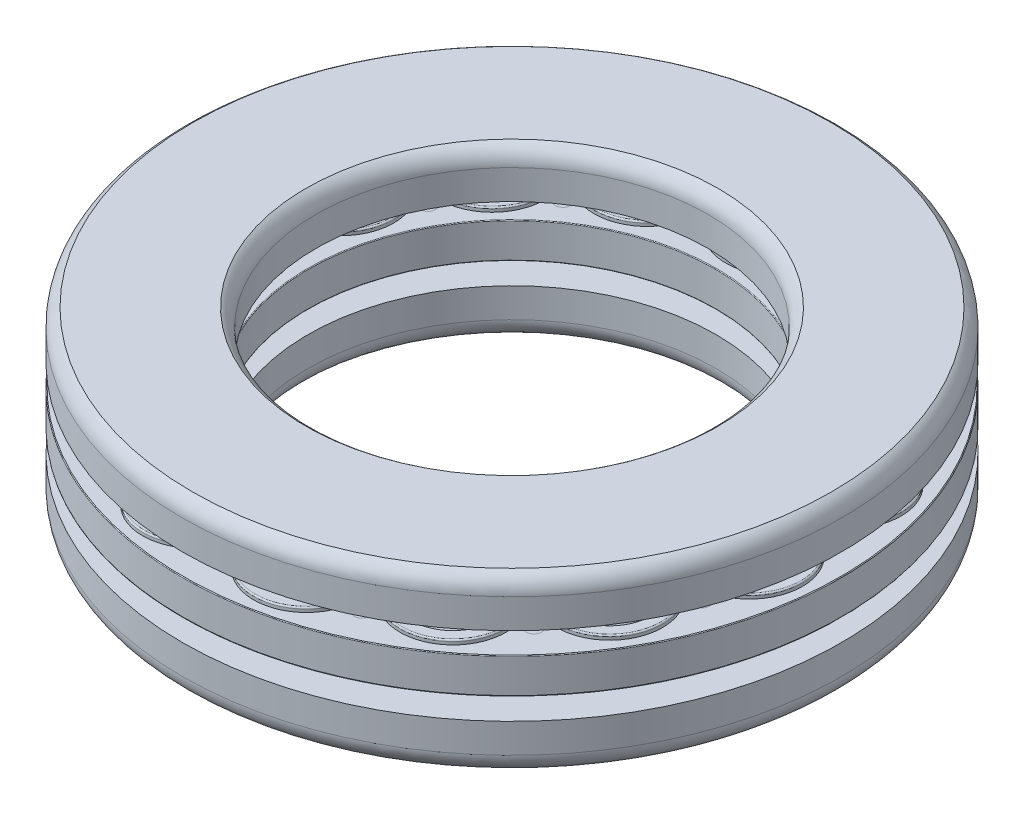
from build123d import *

# Parameters (mm, degrees)
CUT_EXTRUDE1_REACH             = 7.5
CUT_EXTRUDE1_DIRECTION_2_DEPTH = 6.5
SKETCH7_R                      = 0.4995
CUT_EXTRUDE2_DEPTH             = 0.01
CIRPATTERN1_COUNT              = 15
CIRPATTERN2_COUNT              = 15


with BuildPart() as part:
    # Sketch3 → Revolve1 (revolve)
    with BuildSketch(Plane(origin=(0, 0, 0), x_dir=(0, 0, -1), z_dir=(1, 0, 0))):
        with BuildLine():
            Line((21, 2.5), (18.658312395, 2.5))
            ThreePointArc((18.658312395, 2.5), (17, 3), (15.341687605, 2.5))
            Line((15.341687605, 2.5), (12.5, 2.5))
            Line((12.5, 2.5), (12.5, 4.375))
            ThreePointArc((12.5, 4.375), (12.669058766, 5.02038296), (13.1328125, 5.5))
            Line((13.1328125, 5.5), (20.3671875, 5.5))
            ThreePointArc((20.3671875, 5.5), (20.830941234, 5.02038296), (21, 4.375))
            Line((21, 4.375), (21, 2.5))
        make_face()
        with BuildLine():
            Line((15.341687605, -2.5), (13, -2.5))
            Line((13, -2.5), (13, -4.375))
            ThreePointArc((13, -4.375), (13.169058766, -5.02038296), (13.6328125, -5.5))
            Line((13.6328125, -5.5), (20.3671875, -5.5))
            ThreePointArc((20.3671875, -5.5), (20.830941234, -5.02038296), (21, -4.375))
            Line((21, -4.375), (21, -2.5))
            Line((21, -2.5), (18.658312395, -2.5))
            ThreePointArc((18.658312395, -2.5), (17, -3), (15.341687605, -2.5))
        make_face()
        with BuildLine():
            Line((15.875, 1.125), (15.875, 1.31625))
            ThreePointArc((15.875, 1.31625), (15.90136039, 1.37988961), (15.965, 1.40625))
            Line((15.965, 1.40625), (18.035, 1.40625))
            ThreePointArc((18.035, 1.40625), (18.09863961, 1.37988961), (18.125, 1.31625))
            Line((18.125, 1.31625), (18.125, 1.125))
            Line((18.125, 1.125), (20.955, 1.125))
            ThreePointArc((20.955, 1.125), (20.986819805, 1.111819805), (21, 1.08))
            Line((21, 1.08), (21, -1.08))
            ThreePointArc((21, -1.08), (20.986819805, -1.111819805), (20.955, -1.125))
            Line((20.955, -1.125), (18.125, -1.125))
            Line((18.125, -1.125), (18.125, -1.31625))
            ThreePointArc((18.125, -1.31625), (18.09863961, -1.37988961), (18.035, -1.40625))
            Line((18.035, -1.40625), (15.965, -1.40625))
            ThreePointArc((15.965, -1.40625), (15.90136039, -1.37988961), (15.875, -1.31625))
            Line((15.875, -1.31625), (15.875, -1.125))
            Line((15.875, -1.125), (13.045, -1.125))
            ThreePointArc((13.045, -1.125), (13.013180195, -1.111819805), (13, -1.08))
            Line((13, -1.08), (13, 1.08))
            ThreePointArc((13, 1.08), (13.013180195, 1.111819805), (13.045, 1.125))
            Line((13.045, 1.125), (15.875, 1.125))
        make_face()
    revolve(axis=Axis((0, -5.5, 0), (0, 1, 0)))

    # Sketch4 → Revolve2 (revolve)
    with BuildSketch(Plane(origin=(0, 0, 0), x_dir=(0, 0, -1), z_dir=(1, 0, 0))):
        with BuildLine():
            Line((17, 1.40625), (13.715, 1.40625))
            ThreePointArc((13.715, 1.40625), (13.65136039, 1.37988961), (13.625, 1.31625))
            Line((13.625, 1.31625), (13.625, 1.125))
            Line((13.625, 1.125), (17, 1.125))
            Line((17, 1.125), (17, 1.40625))
        make_face()
        with BuildLine():
            Line((13.625, -1.31625), (13.625, -1.125))
            Line((13.625, -1.125), (17, -1.125))
            Line((17, -1.125), (17, -1.40625))
            Line((17, -1.40625), (13.715, -1.40625))
            ThreePointArc((13.715, -1.40625), (13.65136039, -1.37988961), (13.625, -1.31625))
        make_face()
    revolve(axis=Axis((0, 5.5, -17), (0, -1, 0)))

    # Sketch5 → Cut-Extrude1 (cut, up to next)
    with BuildSketch(Plane(origin=(0, 0, 0), x_dir=(1, 0, 0), z_dir=(0, 1, 0)), mode=Mode.PRIVATE) as cut_extrude1_sk1:
        with BuildLine():
            Line((4.911913696, 23.108737067), (0, 0))
            Line((0, 0), (-4.911913696, 23.108737067))
            ThreePointArc((-4.911913696, 23.108737067), (0, -23.625), (4.911913696, 23.108737067))
        make_face()
    cut_extrude1_tool1 = extrude(cut_extrude1_sk1.sketch, amount=-CUT_EXTRUDE1_REACH, mode=Mode.PRIVATE) & part.part
    add(cut_extrude1_tool1.solids().sort_by_distance((0, 0, 1.116793))[0], mode=Mode.SUBTRACT)

    # Sketch5 → Cut-Extrude1 direction 2 (cut)
    with BuildSketch(Plane(origin=(0, 0, 0), x_dir=(1, 0, 0), z_dir=(0, 1, 0))):
        with BuildLine():
            Line((4.911913696, 23.108737067), (0, 0))
            Line((0, 0), (-4.911913696, 23.108737067))
            ThreePointArc((-4.911913696, 23.108737067), (0, -23.625), (4.911913696, 23.108737067))
        make_face()
    extrude(amount=CUT_EXTRUDE1_DIRECTION_2_DEPTH, mode=Mode.SUBTRACT)


with BuildPart() as body_2:
    # Sketch6 → Revolve3 (revolve)
    with BuildSketch(Plane(origin=(0, 0, 0), x_dir=(0, 0, -1), z_dir=(1, 0, 0))):
        with BuildLine():
            Line((17, -3), (17, 3))
            ThreePointArc((17, 3), (14, 0), (17, -3))
        make_face()
    revolve(axis=Axis((0, 5.5, -17), (0, -1, 0)))


with BuildPart() as part_1:
    add(part.part)

    # Combine1: cut body 2
    add(body_2.part, mode=Mode.SUBTRACT)

    # Sketch7 → Cut-Extrude2 (cut)
    with BuildSketch(Plane(origin=(0, 1.125, 0), x_dir=(1, 0, 0), z_dir=(0, 1, 0))):
        with Locations((-3.914587304, 18.416685295)):
            Circle(SKETCH7_R)
        with Locations((-3.04988583, 14.348584707)):
            Circle(SKETCH7_R)
        with Locations((3.04988583, 14.348584707)):
            Circle(SKETCH7_R)
        with Locations((3.914587304, 18.416685295)):
            Circle(SKETCH7_R)
    extrude(amount=-CUT_EXTRUDE2_DEPTH, mode=Mode.SUBTRACT)


with BuildPart() as cirpattern1_1:
    # CirPattern1: pattern copy
    add(part_1.part.rotate(Axis((0, 0, 0), (0, 1, 0)), 1 * 360 / CIRPATTERN1_COUNT))


with BuildPart() as cirpattern1_2:
    # CirPattern1: pattern copy
    add(part_1.part.rotate(Axis((0, 0, 0), (0, 1, 0)), 2 * 360 / CIRPATTERN1_COUNT))


with BuildPart() as cirpattern1_3:
    # CirPattern1: pattern copy
    add(part_1.part.rotate(Axis((0, 0, 0), (0, 1, 0)), 3 * 360 / CIRPATTERN1_COUNT))


with BuildPart() as cirpattern1_4:
    # CirPattern1: pattern copy
    add(part_1.part.rotate(Axis((0, 0, 0), (0, 1, 0)), 4 * 360 / CIRPATTERN1_COUNT))


with BuildPart() as cirpattern1_5:
    # CirPattern1: pattern copy
    add(part_1.part.rotate(Axis((0, 0, 0), (0, 1, 0)), 5 * 360 / CIRPATTERN1_COUNT))


with BuildPart() as cirpattern1_6:
    # CirPattern1: pattern copy
    add(part_1.part.rotate(Axis((0, 0, 0), (0, 1, 0)), 6 * 360 / CIRPATTERN1_COUNT))


with BuildPart() as cirpattern1_7:
    # CirPattern1: pattern copy
    add(part_1.part.rotate(Axis((0, 0, 0), (0, 1, 0)), 7 * 360 / CIRPATTERN1_COUNT))


with BuildPart() as cirpattern1_8:
    # CirPattern1: pattern copy
    add(part_1.part.rotate(Axis((0, 0, 0), (0, 1, 0)), 8 * 360 / CIRPATTERN1_COUNT))


with BuildPart() as cirpattern1_9:
    # CirPattern1: pattern copy
    add(part_1.part.rotate(Axis((0, 0, 0), (0, 1, 0)), 9 * 360 / CIRPATTERN1_COUNT))


with BuildPart() as cirpattern1_10:
    # CirPattern1: pattern copy
    add(part_1.part.rotate(Axis((0, 0, 0), (0, 1, 0)), 10 * 360 / CIRPATTERN1_COUNT))


with BuildPart() as cirpattern1_11:
    # CirPattern1: pattern copy
    add(part_1.part.rotate(Axis((0, 0, 0), (0, 1, 0)), 11 * 360 / CIRPATTERN1_COUNT))


with BuildPart() as cirpattern1_12:
    # CirPattern1: pattern copy
    add(part_1.part.rotate(Axis((0, 0, 0), (0, 1, 0)), 12 * 360 / CIRPATTERN1_COUNT))


with BuildPart() as cirpattern1_13:
    # CirPattern1: pattern copy
    add(part_1.part.rotate(Axis((0, 0, 0), (0, 1, 0)), 13 * 360 / CIRPATTERN1_COUNT))


with BuildPart() as cirpattern1_14:
    # CirPattern1: pattern copy
    add(part_1.part.rotate(Axis((0, 0, 0), (0, 1, 0)), 14 * 360 / CIRPATTERN1_COUNT))


with BuildPart() as part_2:
    add(part_1.part)

    add(cirpattern1_1.part)  # Revolve4 merges CirPattern1_1

    add(cirpattern1_2.part)  # Revolve4 merges CirPattern1_2

    add(cirpattern1_3.part)  # Revolve4 merges CirPattern1_3

    add(cirpattern1_4.part)  # Revolve4 merges CirPattern1_4

    add(cirpattern1_5.part)  # Revolve4 merges CirPattern1_5

    add(cirpattern1_6.part)  # Revolve4 merges CirPattern1_6

    add(cirpattern1_7.part)  # Revolve4 merges CirPattern1_7

    add(cirpattern1_8.part)  # Revolve4 merges CirPattern1_8

    add(cirpattern1_9.part)  # Revolve4 merges CirPattern1_9

    add(cirpattern1_10.part)  # Revolve4 merges CirPattern1_10

    add(cirpattern1_11.part)  # Revolve4 merges CirPattern1_11

    add(cirpattern1_12.part)  # Revolve4 merges CirPattern1_12

    add(cirpattern1_13.part)  # Revolve4 merges CirPattern1_13

    add(cirpattern1_14.part)  # Revolve4 merges CirPattern1_14
    # Sketch8 → Revolve4 (revolve)
    with BuildSketch(Plane(origin=(0, 0, 0), x_dir=(0, 0, -1), z_dir=(1, 0, 0))):
        with BuildLine():
            Line((13.045, -1.125), (13.631962784, -1.125))
            Line((13.631962784, -1.125), (13.631962784, -0.54))
            Line((13.631962784, -0.54), (13, -0.54))
            Line((13, -0.54), (13, -1.08))
            ThreePointArc((13, -1.08), (13.013180195, -1.111819805), (13.045, -1.125))
        make_face()
    revolve(axis=Axis((0, -5.5, 0), (0, 1, 0)))


with BuildPart() as body_2_2:
    # Sketch6_2 → Revolve5 (revolve)
    with BuildSketch(Plane(origin=(0, 0, 0), x_dir=(0, 0, -1), z_dir=(1, 0, 0))):
        with BuildLine():
            Line((17, -3), (17, 3))
            ThreePointArc((17, 3), (14, 0), (17, -3))
        make_face()
    revolve(axis=Axis((0, 5.5, -17), (0, -1, 0)))


with BuildPart() as cirpattern2_1:
    # CirPattern2: pattern copy
    add(body_2_2.part.rotate(Axis((0, 0, 0), (0, 1, 0)), 1 * 360 / CIRPATTERN2_COUNT))


with BuildPart() as cirpattern2_2:
    # CirPattern2: pattern copy
    add(body_2_2.part.rotate(Axis((0, 0, 0), (0, 1, 0)), 2 * 360 / CIRPATTERN2_COUNT))


with BuildPart() as cirpattern2_3:
    # CirPattern2: pattern copy
    add(body_2_2.part.rotate(Axis((0, 0, 0), (0, 1, 0)), 3 * 360 / CIRPATTERN2_COUNT))


with BuildPart() as cirpattern2_4:
    # CirPattern2: pattern copy
    add(body_2_2.part.rotate(Axis((0, 0, 0), (0, 1, 0)), 4 * 360 / CIRPATTERN2_COUNT))


with BuildPart() as cirpattern2_5:
    # CirPattern2: pattern copy
    add(body_2_2.part.rotate(Axis((0, 0, 0), (0, 1, 0)), 5 * 360 / CIRPATTERN2_COUNT))


with BuildPart() as cirpattern2_6:
    # CirPattern2: pattern copy
    add(body_2_2.part.rotate(Axis((0, 0, 0), (0, 1, 0)), 6 * 360 / CIRPATTERN2_COUNT))


with BuildPart() as cirpattern2_7:
    # CirPattern2: pattern copy
    add(body_2_2.part.rotate(Axis((0, 0, 0), (0, 1, 0)), 7 * 360 / CIRPATTERN2_COUNT))


with BuildPart() as cirpattern2_8:
    # CirPattern2: pattern copy
    add(body_2_2.part.rotate(Axis((0, 0, 0), (0, 1, 0)), 8 * 360 / CIRPATTERN2_COUNT))


with BuildPart() as cirpattern2_9:
    # CirPattern2: pattern copy
    add(body_2_2.part.rotate(Axis((0, 0, 0), (0, 1, 0)), 9 * 360 / CIRPATTERN2_COUNT))


with BuildPart() as cirpattern2_10:
    # CirPattern2: pattern copy
    add(body_2_2.part.rotate(Axis((0, 0, 0), (0, 1, 0)), 10 * 360 / CIRPATTERN2_COUNT))


with BuildPart() as cirpattern2_11:
    # CirPattern2: pattern copy
    add(body_2_2.part.rotate(Axis((0, 0, 0), (0, 1, 0)), 11 * 360 / CIRPATTERN2_COUNT))


with BuildPart() as cirpattern2_12:
    # CirPattern2: pattern copy
    add(body_2_2.part.rotate(Axis((0, 0, 0), (0, 1, 0)), 12 * 360 / CIRPATTERN2_COUNT))


with BuildPart() as cirpattern2_13:
    # CirPattern2: pattern copy
    add(body_2_2.part.rotate(Axis((0, 0, 0), (0, 1, 0)), 13 * 360 / CIRPATTERN2_COUNT))


with BuildPart() as cirpattern2_14:
    # CirPattern2: pattern copy
    add(body_2_2.part.rotate(Axis((0, 0, 0), (0, 1, 0)), 14 * 360 / CIRPATTERN2_COUNT))


solid = Compound([part_2.part, body_2_2.part, cirpattern2_1.part, cirpattern2_2.part, cirpattern2_3.part, cirpattern2_4.part, cirpattern2_5.part, cirpattern2_6.part, cirpattern2_7.part, cirpattern2_8.part, cirpattern2_9.part, cirpattern2_10.part, cirpattern2_11.part, cirpattern2_12.part, cirpattern2_13.part, cirpattern2_14.part])
